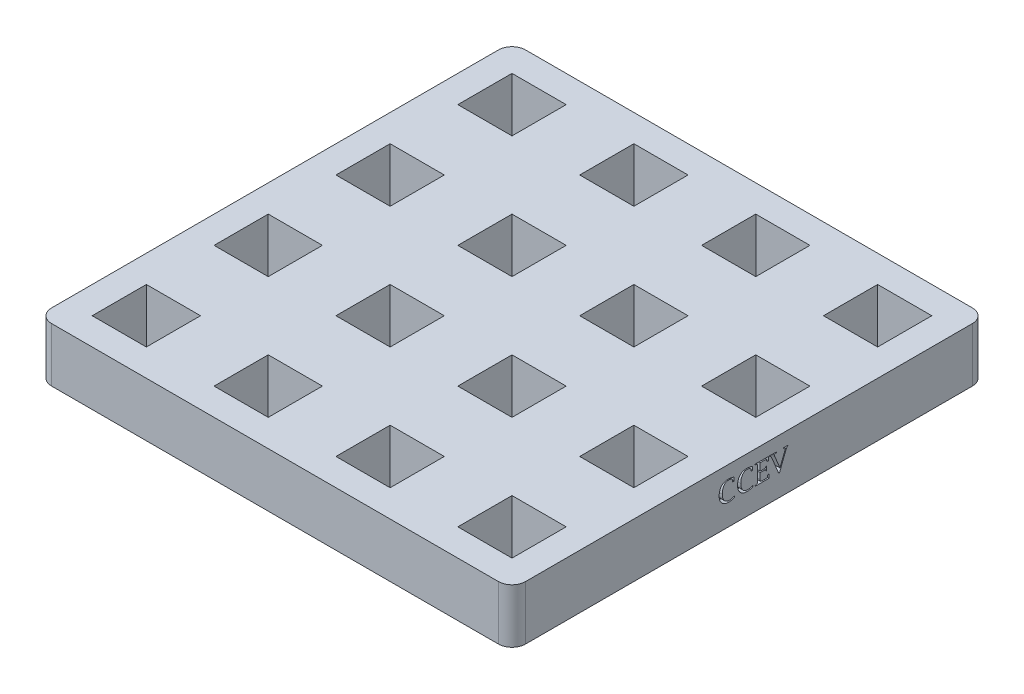
from build123d import *

# Parameters (mm, degrees)
SKETCH1_W           = 88.9
SKETCH1_H           = 88.9
SKETCH1_W_2         = 10.16
SKETCH1_H_2         = 10.16
BOSS_EXTRUDE1_DEPTH = 10.16
CUT_EXTRUDE2_DEPTH  = 1.27
FILLET1_R           = 2.54


with BuildPart() as part:
    # Sketch1 → Boss-Extrude1 (new body)
    with BuildSketch(Plane(origin=(0, 0, 0), x_dir=(1, 0, 0), z_dir=(0, 1, 0))):
        with Locations((44.45, -44.45)):
            Rectangle(SKETCH1_W, SKETCH1_H)
        with Locations((33.02, -10.16)):
            Rectangle(SKETCH1_W_2, SKETCH1_H_2, mode=Mode.SUBTRACT)
        with Locations((10.16, -10.16)):
            Rectangle(SKETCH1_W_2, SKETCH1_H_2, mode=Mode.SUBTRACT)
        with Locations((55.88, -10.16)):
            Rectangle(SKETCH1_W_2, SKETCH1_H_2, mode=Mode.SUBTRACT)
        with Locations((78.74, -10.16)):
            Rectangle(SKETCH1_W_2, SKETCH1_H_2, mode=Mode.SUBTRACT)
        with Locations((33.02, -33.02)):
            Rectangle(SKETCH1_W_2, SKETCH1_H_2, mode=Mode.SUBTRACT)
        with Locations((55.88, -33.02)):
            Rectangle(SKETCH1_W_2, SKETCH1_H_2, mode=Mode.SUBTRACT)
        with Locations((78.74, -33.02)):
            Rectangle(SKETCH1_W_2, SKETCH1_H_2, mode=Mode.SUBTRACT)
        with Locations((33.02, -55.88)):
            Rectangle(SKETCH1_W_2, SKETCH1_H_2, mode=Mode.SUBTRACT)
        with Locations((55.88, -55.88)):
            Rectangle(SKETCH1_W_2, SKETCH1_H_2, mode=Mode.SUBTRACT)
        with Locations((78.74, -55.88)):
            Rectangle(SKETCH1_W_2, SKETCH1_H_2, mode=Mode.SUBTRACT)
        with Locations((33.02, -78.74)):
            Rectangle(SKETCH1_W_2, SKETCH1_H_2, mode=Mode.SUBTRACT)
        with Locations((55.88, -78.74)):
            Rectangle(SKETCH1_W_2, SKETCH1_H_2, mode=Mode.SUBTRACT)
        with Locations((78.74, -78.74)):
            Rectangle(SKETCH1_W_2, SKETCH1_H_2, mode=Mode.SUBTRACT)
        with Locations((10.16, -33.02)):
            Rectangle(SKETCH1_W_2, SKETCH1_H_2, mode=Mode.SUBTRACT)
        with Locations((10.16, -55.88)):
            Rectangle(SKETCH1_W_2, SKETCH1_H_2, mode=Mode.SUBTRACT)
        with Locations((10.16, -78.74)):
            Rectangle(SKETCH1_W_2, SKETCH1_H_2, mode=Mode.SUBTRACT)
    extrude(amount=BOSS_EXTRUDE1_DEPTH)

    # Sketch3 → Cut-Extrude2 (cut)
    with BuildSketch(Plane(origin=(88.9, 0, 0), x_dir=(0, 0, -1), z_dir=(1, 0, 0))):
        with BuildLine():
            add(Edge.make_bspline(
                [(-47.143700699, 4.285314676), (-47.184685, 4.26307936), (-47.266892715, 4.218479002), (-47.396440466, 4.16267377), (-47.530482003, 4.115100858), (-47.66953927, 4.075984169), (-47.813710656, 4.045866927), (-47.962867146, 4.024480822), (-48.117035844, 4.01108947), (-48.221454478, 4.009522956), (-48.274542941, 4.00872651)],
                knots=[0, 0, 0, 0, 0.950097763, 1.905738653, 2.871688724, 3.847851376, 4.848060568, 5.871763302, 6.917963107, 8, 8, 8, 8], degree=3))
            add(Edge.make_bspline(
                [(-48.274542941, 4.00872651), (-48.341364018, 4.010174823), (-48.472084907, 4.013008134), (-48.662554011, 4.037248798), (-48.842518678, 4.076283775), (-49.011030142, 4.133004539), (-49.169107063, 4.204107624), (-49.316017016, 4.292174019), (-49.451626441, 4.396272751), (-49.576036708, 4.515398595), (-49.686469564, 4.648774633), (-49.783871499, 4.793842529), (-49.866337949, 4.950658186), (-49.932372813, 5.11976799), (-49.984234523, 5.299914249), (-50.021509532, 5.491724077), (-50.044120797, 5.695081268), (-50.046605356, 5.834581126), (-50.047876443, 5.905948461)],
                knots=[0, 0, 0, 0, 1.0907127, 2.133741934, 3.129613494, 4.092881734, 5.031519219, 5.954636873, 6.883025615, 7.817429068, 8.761096259, 9.704885592, 10.665853524, 11.647925027, 12.664084858, 13.722792364, 14.834993506, 16, 16, 16, 16], degree=3))
            add(Edge.make_bspline(
                [(-50.047876443, 5.905948461), (-50.046504565, 5.978268141), (-50.043832278, 6.11914), (-50.022789266, 6.324341803), (-49.987933102, 6.517419663), (-49.938264127, 6.697982596), (-49.875004267, 6.866401951), (-49.796771669, 7.021963916), (-49.705253467, 7.165685024), (-49.598831823, 7.295686418), (-49.479821095, 7.412030173), (-49.348860807, 7.513365753), (-49.206565881, 7.599117733), (-49.052613455, 7.66833081), (-48.887420317, 7.722378592), (-48.711065062, 7.761030368), (-48.523423982, 7.784336929), (-48.39465813, 7.787262907), (-48.328564067, 7.788764779)],
                knots=[0, 0, 0, 0, 1.198437993, 2.334443252, 3.414667221, 4.446694533, 5.434080735, 6.391511889, 7.327567475, 8.252356355, 9.169726966, 10.0802973, 10.990685018, 11.916765772, 12.871878647, 13.866328085, 14.904810219, 16, 16, 16, 16], degree=3))
            add(Edge.make_bspline(
                [(-48.328564067, 7.788764779), (-48.292535173, 7.788160024), (-48.217502334, 7.786900575), (-48.101192253, 7.777752223), (-47.976761016, 7.763188329), (-47.844186383, 7.742807823), (-47.703415896, 7.716939563), (-47.554587432, 7.684864886), (-47.397715223, 7.647592435), (-47.290811593, 7.619039761), (-47.235896754, 7.604372669)],
                knots=[0, 0, 0, 0, 0.778211485, 1.620683054, 2.518725369, 3.483977919, 4.517483666, 5.609946115, 6.772264103, 8, 8, 8, 8], degree=3))
            Line((-47.235896754, 7.604372669), (-47.235896754, 6.912902254))
            Line((-47.235896754, 6.912902254), (-47.512484921, 6.912902254))
            Line((-47.512484921, 6.912902254), (-47.512484921, 6.960440845))
            add(Edge.make_bspline(
                [(-47.512484921, 6.960440845), (-47.512484921, 6.98421014), (-47.512484921, 7.031268543), (-47.512484921, 7.078326947), (-47.512484921, 7.101616054)],
                knots=[0, 0, 0, 0, 1.010204082, 2, 2, 2, 2], degree=3))
            add(Edge.make_bspline(
                [(-47.512484921, 7.101616054), (-47.513264842, 7.120617659), (-47.514785028, 7.157654717), (-47.524152336, 7.212028887), (-47.540841922, 7.26307757), (-47.563813484, 7.311449349), (-47.595122106, 7.355356918), (-47.630833242, 7.397862715), (-47.674861574, 7.435804612), (-47.724492485, 7.471097535), (-47.779843361, 7.502495814), (-47.840057368, 7.530049764), (-47.905161342, 7.553091235), (-47.97536449, 7.571446227), (-48.050049494, 7.586952518), (-48.129824154, 7.596368922), (-48.213918143, 7.603277877), (-48.271646062, 7.604002024), (-48.301193363, 7.604372669)],
                knots=[0, 0, 0, 0, 0.872940392, 1.70149544, 2.524527953, 3.333401312, 4.150129811, 4.994603991, 5.877449129, 6.810717511, 7.788717292, 8.795394151, 9.848766788, 10.956224994, 12.126265042, 13.349109787, 14.643175601, 16, 16, 16, 16], degree=3))
            add(Edge.make_bspline(
                [(-48.301193363, 7.604372669), (-48.343782483, 7.603036197), (-48.427369247, 7.600413195), (-48.549488051, 7.578327432), (-48.664802172, 7.541566155), (-48.773339273, 7.489547501), (-48.875492616, 7.423793561), (-48.970417033, 7.342724959), (-49.058850403, 7.247504119), (-49.139449678, 7.13824451), (-49.212091302, 7.017081382), (-49.275515819, 6.885377204), (-49.329317935, 6.744151341), (-49.373574215, 6.593183545), (-49.406772679, 6.432425926), (-49.431351081, 6.261915644), (-49.445657664, 6.081702416), (-49.44760508, 5.958314281), (-49.448602083, 5.895144236)],
                knots=[0, 0, 0, 0, 0.888373946, 1.743551007, 2.580294788, 3.407379563, 4.248314273, 5.108731313, 6.00576896, 6.954874221, 7.937159125, 8.950188932, 10.001809612, 11.088010484, 12.230028994, 13.42485153, 14.681621673, 16, 16, 16, 16], degree=3))
            add(Edge.make_bspline(
                [(-49.448602083, 5.895144236), (-49.447572011, 5.831716162), (-49.44557022, 5.708453247), (-49.42788412, 5.528897929), (-49.399624151, 5.359991457), (-49.359088793, 5.201806839), (-49.308552453, 5.053752509), (-49.244373377, 4.917174534), (-49.170707123, 4.790076463), (-49.083778174, 4.675522611), (-48.987074178, 4.572733092), (-48.88102008, 4.482875189), (-48.765475428, 4.407424825), (-48.641091237, 4.345946181), (-48.507924168, 4.297104049), (-48.365126077, 4.264201453), (-48.213998619, 4.242268925), (-48.110160148, 4.240249927), (-48.057017872, 4.239216648)],
                knots=[0, 0, 0, 0, 1.242005494, 2.413650741, 3.529974997, 4.592937592, 5.608668543, 6.589038791, 7.54391707, 8.480640935, 9.398755183, 10.303097998, 11.196518338, 12.094493543, 13.015313349, 13.967687329, 14.959906499, 16, 16, 16, 16], degree=3))
            add(Edge.make_bspline(
                [(-48.057017872, 4.239216648), (-48.02096602, 4.240062527), (-47.948155753, 4.241770862), (-47.83813366, 4.255434786), (-47.726245815, 4.277121978), (-47.612621386, 4.307350865), (-47.497509876, 4.346711257), (-47.380735009, 4.394528843), (-47.261766727, 4.450455365), (-47.183560317, 4.493742549), (-47.143700699, 4.515804814)],
                knots=[0, 0, 0, 0, 0.896500142, 1.810570349, 2.753391962, 3.729718686, 4.732516545, 5.777170997, 6.867086282, 8, 8, 8, 8], degree=3))
            Line((-47.143700699, 4.515804814), (-47.143700699, 4.285314676))
        make_face()
        with BuildLine():
            add(Edge.make_bspline(
                [(-43.686348623, 4.285314676), (-43.727332924, 4.26307936), (-43.809540639, 4.218479002), (-43.93908839, 4.16267377), (-44.073129927, 4.115100858), (-44.212187195, 4.075984169), (-44.356358581, 4.045866927), (-44.50551507, 4.024480822), (-44.659683768, 4.01108947), (-44.764102402, 4.009522956), (-44.817190865, 4.00872651)],
                knots=[0, 0, 0, 0, 0.950097763, 1.905738653, 2.871688724, 3.847851376, 4.848060568, 5.871763302, 6.917963107, 8, 8, 8, 8], degree=3))
            add(Edge.make_bspline(
                [(-44.817190865, 4.00872651), (-44.884011942, 4.010174823), (-45.014732831, 4.013008134), (-45.205201935, 4.037248798), (-45.385166602, 4.076283775), (-45.553678067, 4.133004539), (-45.711754987, 4.204107624), (-45.85866494, 4.292174019), (-45.994274366, 4.396272751), (-46.118684632, 4.515398595), (-46.229117488, 4.648774633), (-46.326519423, 4.793842529), (-46.408985873, 4.950658186), (-46.475020737, 5.11976799), (-46.526882447, 5.299914249), (-46.564157456, 5.491724077), (-46.586768721, 5.695081268), (-46.58925328, 5.834581126), (-46.590524367, 5.905948461)],
                knots=[0, 0, 0, 0, 1.0907127, 2.133741934, 3.129613494, 4.092881734, 5.031519219, 5.954636873, 6.883025615, 7.817429068, 8.761096259, 9.704885592, 10.665853524, 11.647925027, 12.664084858, 13.722792364, 14.834993506, 16, 16, 16, 16], degree=3))
            add(Edge.make_bspline(
                [(-46.590524367, 5.905948461), (-46.589152489, 5.978268141), (-46.586480202, 6.11914), (-46.56543719, 6.324341803), (-46.530581026, 6.517419663), (-46.480912051, 6.697982596), (-46.417652191, 6.866401951), (-46.339419593, 7.021963916), (-46.247901391, 7.165685024), (-46.141479748, 7.295686418), (-46.02246902, 7.412030173), (-45.891508731, 7.513365753), (-45.749213805, 7.599117733), (-45.595261379, 7.66833081), (-45.430068241, 7.722378592), (-45.253712986, 7.761030368), (-45.066071907, 7.784336929), (-44.937306054, 7.787262907), (-44.871211991, 7.788764779)],
                knots=[0, 0, 0, 0, 1.198437993, 2.334443252, 3.414667221, 4.446694533, 5.434080735, 6.391511889, 7.327567475, 8.252356355, 9.169726966, 10.0802973, 10.990685018, 11.916765772, 12.871878647, 13.866328085, 14.904810219, 16, 16, 16, 16], degree=3))
            add(Edge.make_bspline(
                [(-44.871211991, 7.788764779), (-44.835183097, 7.788160024), (-44.760150258, 7.786900575), (-44.643840177, 7.777752223), (-44.519408941, 7.763188329), (-44.386834307, 7.742807823), (-44.24606382, 7.716939563), (-44.097235356, 7.684864886), (-43.940363147, 7.647592435), (-43.833459517, 7.619039761), (-43.778544679, 7.604372669)],
                knots=[0, 0, 0, 0, 0.778211485, 1.620683054, 2.518725369, 3.483977919, 4.517483666, 5.609946115, 6.772264103, 8, 8, 8, 8], degree=3))
            Line((-43.778544679, 7.604372669), (-43.778544679, 6.912902254))
            Line((-43.778544679, 6.912902254), (-44.055132845, 6.912902254))
            Line((-44.055132845, 6.912902254), (-44.055132845, 6.960440845))
            add(Edge.make_bspline(
                [(-44.055132845, 6.960440845), (-44.055132845, 6.98421014), (-44.055132845, 7.031268543), (-44.055132845, 7.078326947), (-44.055132845, 7.101616054)],
                knots=[0, 0, 0, 0, 1.010204082, 2, 2, 2, 2], degree=3))
            add(Edge.make_bspline(
                [(-44.055132845, 7.101616054), (-44.055912766, 7.120617659), (-44.057432953, 7.157654717), (-44.06680026, 7.212028887), (-44.083489846, 7.26307757), (-44.106461408, 7.311449349), (-44.13777003, 7.355356918), (-44.173481166, 7.397862715), (-44.217509499, 7.435804612), (-44.267140409, 7.471097535), (-44.322491285, 7.502495814), (-44.382705292, 7.530049764), (-44.447809267, 7.553091235), (-44.518012414, 7.571446227), (-44.592697418, 7.586952518), (-44.672472078, 7.596368922), (-44.756566067, 7.603277877), (-44.814293987, 7.604002024), (-44.843841287, 7.604372669)],
                knots=[0, 0, 0, 0, 0.872940392, 1.70149544, 2.524527953, 3.333401312, 4.150129811, 4.994603991, 5.877449129, 6.810717511, 7.788717292, 8.795394151, 9.848766788, 10.956224994, 12.126265042, 13.349109787, 14.643175601, 16, 16, 16, 16], degree=3))
            add(Edge.make_bspline(
                [(-44.843841287, 7.604372669), (-44.886430407, 7.603036197), (-44.970017171, 7.600413195), (-45.092135975, 7.578327432), (-45.207450096, 7.541566155), (-45.315987197, 7.489547501), (-45.41814054, 7.423793561), (-45.513064957, 7.342724959), (-45.601498327, 7.247504119), (-45.682097602, 7.13824451), (-45.754739226, 7.017081382), (-45.818163743, 6.885377204), (-45.871965859, 6.744151341), (-45.916222139, 6.593183545), (-45.949420603, 6.432425926), (-45.973999005, 6.261915644), (-45.988305588, 6.081702416), (-45.990253004, 5.958314281), (-45.991250007, 5.895144236)],
                knots=[0, 0, 0, 0, 0.888373946, 1.743551007, 2.580294788, 3.407379563, 4.248314273, 5.108731313, 6.00576896, 6.954874221, 7.937159125, 8.950188932, 10.001809612, 11.088010484, 12.230028994, 13.42485153, 14.681621673, 16, 16, 16, 16], degree=3))
            add(Edge.make_bspline(
                [(-45.991250007, 5.895144236), (-45.990219935, 5.831716162), (-45.988218144, 5.708453247), (-45.970532044, 5.528897929), (-45.942272075, 5.359991457), (-45.901736717, 5.201806839), (-45.851200377, 5.053752509), (-45.787021302, 4.917174534), (-45.713355048, 4.790076463), (-45.626426098, 4.675522611), (-45.529722102, 4.572733092), (-45.423668004, 4.482875189), (-45.308123352, 4.407424825), (-45.183739161, 4.345946181), (-45.050572092, 4.297104049), (-44.907774001, 4.264201453), (-44.756646543, 4.242268925), (-44.652808072, 4.240249927), (-44.599665797, 4.239216648)],
                knots=[0, 0, 0, 0, 1.242005494, 2.413650741, 3.529974997, 4.592937592, 5.608668543, 6.589038791, 7.54391707, 8.480640935, 9.398755183, 10.303097998, 11.196518338, 12.094493543, 13.015313349, 13.967687329, 14.959906499, 16, 16, 16, 16], degree=3))
            add(Edge.make_bspline(
                [(-44.599665797, 4.239216648), (-44.563613944, 4.240062527), (-44.490803677, 4.241770862), (-44.380781584, 4.255434786), (-44.268893739, 4.277121978), (-44.15526931, 4.307350865), (-44.0401578, 4.346711257), (-43.923382933, 4.394528843), (-43.804414651, 4.450455365), (-43.726208241, 4.493742549), (-43.686348623, 4.515804814)],
                knots=[0, 0, 0, 0, 0.896500142, 1.810570349, 2.753391962, 3.729718686, 4.732516545, 5.777170997, 6.867086282, 8, 8, 8, 8], degree=3))
            Line((-43.686348623, 4.515804814), (-43.686348623, 4.285314676))
        make_face()
        with BuildLine():
            Line((-40.689976824, 4.100922565), (-43.317564402, 4.100922565))
            Line((-43.317564402, 4.100922565), (-43.317564402, 4.239216648))
            Line((-43.317564402, 4.239216648), (-43.270025811, 4.242097775))
            add(Edge.make_bspline(
                [(-43.270025811, 4.242097775), (-43.246240461, 4.243854333), (-43.201007682, 4.247194792), (-43.137123008, 4.254456648), (-43.080695897, 4.262469003), (-43.032355456, 4.273819324), (-42.990959551, 4.284398866), (-42.957816759, 4.298275947), (-42.931476202, 4.312357079), (-42.911487932, 4.330000307), (-42.898087494, 4.354217789), (-42.886923067, 4.384850391), (-42.876991537, 4.423936291), (-42.869374537, 4.471660941), (-42.863966174, 4.527968204), (-42.859741255, 4.593064784), (-42.856744076, 4.666796627), (-42.856639202, 4.718920958), (-42.856584125, 4.746294953)],
                knots=[0, 0, 0, 0, 1.434223856, 2.727474356, 3.867048795, 4.858481374, 5.713375648, 6.432048766, 7.014145389, 7.504681859, 8.009876932, 8.658876013, 9.464418017, 10.430606696, 11.562838439, 12.865326848, 14.353772105, 16, 16, 16, 16], degree=3))
            Line((-42.856584125, 4.746294953), (-42.856584125, 7.051196337))
            add(Edge.make_bspline(
                [(-42.856584125, 7.051196337), (-42.856636384, 7.078810429), (-42.856735482, 7.13117485), (-42.85973999, 7.205147217), (-42.863969524, 7.270242069), (-42.869364561, 7.326554537), (-42.877020696, 7.374263851), (-42.886786278, 7.413175587), (-42.898069914, 7.443298618), (-42.911500144, 7.466879962), (-42.931755592, 7.483584623), (-42.957618534, 7.497976636), (-42.991184798, 7.510604266), (-43.032209808, 7.521857706), (-43.080896763, 7.53160858), (-43.137012195, 7.541273628), (-43.201029334, 7.548015897), (-43.246247923, 7.551434841), (-43.270025811, 7.553232669)],
                knots=[0, 0, 0, 0, 1.663492872, 3.154470594, 4.459175079, 5.59333322, 6.561165788, 7.368078355, 8.00468548, 8.498392893, 8.980088247, 9.563175259, 10.277674215, 11.13402302, 12.124082947, 13.267885073, 14.563335932, 16, 16, 16, 16], degree=3))
            Line((-43.270025811, 7.553232669), (-43.317564402, 7.558274641))
            Line((-43.317564402, 7.558274641), (-43.317564402, 7.696568724))
            Line((-43.317564402, 7.696568724), (-40.828270907, 7.696568724))
            Line((-40.828270907, 7.696568724), (-40.828270907, 7.005098309))
            Line((-40.828270907, 7.005098309), (-41.104859073, 7.005098309))
            Line((-41.104859073, 7.005098309), (-41.109901045, 7.054077463))
            add(Edge.make_bspline(
                [(-41.109901045, 7.054077463), (-41.111449795, 7.081937577), (-41.11436208, 7.13432599), (-41.120417027, 7.207760902), (-41.125712703, 7.271224633), (-41.13238139, 7.324267614), (-41.138321282, 7.367130462), (-41.14560607, 7.399694497), (-41.151976203, 7.42230316), (-41.16055357, 7.438621449), (-41.178085438, 7.445156966), (-41.201554361, 7.451771135), (-41.236728238, 7.454717054), (-41.281677189, 7.45977402), (-41.337767205, 7.461707268), (-41.404209628, 7.465446487), (-41.481574172, 7.465174714), (-41.536550689, 7.465764421), (-41.56583935, 7.466078586)],
                knots=[0, 0, 0, 0, 1.682356696, 3.163518976, 4.442725569, 5.521898355, 6.385906316, 7.053251075, 7.524801867, 7.817933519, 8.109272299, 8.604453009, 9.304744283, 10.220905803, 11.337117878, 12.684699471, 14.233778341, 16, 16, 16, 16], degree=3))
            Line((-41.56583935, 7.466078586), (-42.349505821, 7.466078586))
            Line((-42.349505821, 7.466078586), (-42.349505821, 6.083137755))
            Line((-42.349505821, 6.083137755), (-41.658035405, 6.083137755))
            add(Edge.make_bspline(
                [(-41.658035405, 6.083137755), (-41.638585037, 6.082973762), (-41.601838784, 6.08266394), (-41.549758799, 6.084715206), (-41.50336386, 6.085464517), (-41.463063891, 6.088742506), (-41.42844771, 6.09138932), (-41.399804906, 6.094843024), (-41.376936905, 6.099006425), (-41.358758209, 6.103721377), (-41.34404917, 6.112674086), (-41.331924364, 6.12672904), (-41.322270028, 6.146276653), (-41.312438015, 6.1701375), (-41.306186812, 6.199955944), (-41.299080663, 6.234619275), (-41.295518501, 6.274945656), (-41.293303527, 6.303546525), (-41.292132311, 6.318669865)],
                knots=[0, 0, 0, 0, 1.750346813, 3.306810787, 4.690475985, 5.925230668, 6.944535533, 7.815631037, 8.519176265, 9.038697147, 9.49454414, 10.04547331, 10.683585927, 11.450028129, 12.361978174, 13.417296017, 14.634338332, 16, 16, 16, 16], degree=3))
            Line((-41.292132311, 6.318669865), (-41.289251184, 6.359725921))
            Line((-41.289251184, 6.359725921), (-41.150957101, 6.359725921))
            Line((-41.150957101, 6.359725921), (-41.150957101, 5.576059451))
            Line((-41.150957101, 5.576059451), (-41.289251184, 5.576059451))
            Line((-41.289251184, 5.576059451), (-41.292132311, 5.616395225))
            add(Edge.make_bspline(
                [(-41.292132311, 5.616395225), (-41.294087109, 5.642188907), (-41.297571604, 5.688167023), (-41.310990285, 5.748382173), (-41.328586674, 5.79322764), (-41.352880474, 5.817823401), (-41.376517588, 5.828685727), (-41.399743591, 5.834553289), (-41.428370658, 5.840189284), (-41.46294164, 5.845432033), (-41.503363132, 5.848709789), (-41.549737513, 5.850667106), (-41.601844824, 5.852147164), (-41.638586672, 5.8524744), (-41.658035405, 5.852647617)],
                knots=[0, 0, 0, 0, 1.775991818, 3.165765901, 4.237076321, 5.04274036, 5.463690792, 6.012543005, 6.686063696, 7.47064192, 8.415384781, 9.473251275, 10.662504301, 12, 12, 12, 12], degree=3))
            Line((-41.658035405, 5.852647617), (-42.349505821, 5.852647617))
            Line((-42.349505821, 5.852647617), (-42.349505821, 4.741252981))
            add(Edge.make_bspline(
                [(-42.349505821, 4.741252981), (-42.349092951, 4.719406585), (-42.348307694, 4.677855776), (-42.346157573, 4.618884664), (-42.339767203, 4.566608884), (-42.333496819, 4.520386411), (-42.3229725, 4.480862698), (-42.312212098, 4.446984705), (-42.297593436, 4.420276779), (-42.281181316, 4.398039845), (-42.258442446, 4.381606863), (-42.230021374, 4.368314181), (-42.194935621, 4.356793553), (-42.153082677, 4.348063283), (-42.104631917, 4.339653474), (-42.048954047, 4.335490523), (-41.986545397, 4.331310005), (-41.942556372, 4.331377384), (-41.919497656, 4.331412704)],
                knots=[0, 0, 0, 0, 1.439586269, 2.738024779, 3.883770786, 4.908264219, 5.805872399, 6.576152683, 7.241357454, 7.804542437, 8.380246611, 9.06636846, 9.866592182, 10.806668816, 11.880514564, 13.103353883, 14.481599867, 16, 16, 16, 16], degree=3))
            Line((-41.919497656, 4.331412704), (-41.519741322, 4.331412704))
            add(Edge.make_bspline(
                [(-41.519741322, 4.331412704), (-41.486845284, 4.331497985), (-41.424646889, 4.331659231), (-41.33702664, 4.334226753), (-41.26058273, 4.336245403), (-41.195568392, 4.341901679), (-41.141555662, 4.346628086), (-41.098764078, 4.354852171), (-41.066951027, 4.362660357), (-41.043182551, 4.372823587), (-41.027751402, 4.391355583), (-41.015368964, 4.416229924), (-41.004037457, 4.449971318), (-40.994379855, 4.492464719), (-40.985913756, 4.543711283), (-40.978811769, 4.603801001), (-40.973354858, 4.672780605), (-40.970327517, 4.721800479), (-40.968725835, 4.747735516)],
                knots=[0, 0, 0, 0, 1.820585629, 3.442283955, 4.851877284, 6.051462577, 7.053760755, 7.851297732, 8.457350782, 8.873349519, 9.249677194, 9.760899543, 10.408096276, 11.213893541, 12.170764456, 13.281693943, 14.561820661, 16, 16, 16, 16], degree=3))
            Line((-40.968725835, 4.747735516), (-40.96656499, 4.79239298))
            Line((-40.96656499, 4.79239298), (-40.689976824, 4.79239298))
            Line((-40.689976824, 4.79239298), (-40.689976824, 4.100922565))
        make_face()
        with BuildLine():
            Line((-38.879188675, 4.00872651), (-40.123835422, 7.047594928))
            add(Edge.make_bspline(
                [(-40.123835422, 7.047594928), (-40.136587969, 7.076633557), (-40.160838293, 7.131853598), (-40.194771914, 7.210283931), (-40.226807724, 7.278336877), (-40.254105975, 7.33743045), (-40.278440501, 7.386606745), (-40.29901117, 7.426827019), (-40.317294448, 7.456631822), (-40.335011126, 7.486173761), (-40.365465785, 7.51289165), (-40.413570069, 7.533822161), (-40.475138726, 7.547572361), (-40.520870893, 7.551229492), (-40.545920488, 7.553232669)],
                knots=[0, 0, 0, 0, 1.602672807, 3.047652762, 4.317853151, 5.403348134, 6.336598002, 7.090957004, 7.683957734, 8.104586903, 8.826031991, 9.68357985, 10.731190977, 12, 12, 12, 12], degree=3))
            Line((-40.545920488, 7.553232669), (-40.597780769, 7.558274641))
            Line((-40.597780769, 7.558274641), (-40.597780769, 7.696568724))
            Line((-40.597780769, 7.696568724), (-39.30127374, 7.696568724))
            Line((-39.30127374, 7.696568724), (-39.30127374, 7.558274641))
            Line((-39.30127374, 7.558274641), (-39.354574585, 7.558274641))
            add(Edge.make_bspline(
                [(-39.354574585, 7.558274641), (-39.383879223, 7.558140776), (-39.438697298, 7.557890364), (-39.514832282, 7.552479543), (-39.57969682, 7.545960862), (-39.63289352, 7.535746119), (-39.674873514, 7.521917435), (-39.704827707, 7.5046198), (-39.726185698, 7.484088009), (-39.728676381, 7.46691027), (-39.729841342, 7.458875769)],
                knots=[0, 0, 0, 0, 1.709845997, 3.198485699, 4.453512714, 5.511582557, 6.358080189, 7.011764801, 7.537775178, 8, 8, 8, 8], degree=3))
            add(Edge.make_bspline(
                [(-39.729841342, 7.458875769), (-39.72924067, 7.453809191), (-39.727582028, 7.439818786), (-39.719177221, 7.414138573), (-39.708250322, 7.377738548), (-39.691630403, 7.331150044), (-39.672049066, 7.273721383), (-39.646246114, 7.206070316), (-39.617155928, 7.127542567), (-39.595258996, 7.072042609), (-39.58362416, 7.042552956)],
                knots=[0, 0, 0, 0, 0.27672885, 0.764134872, 1.461408599, 2.3442464, 3.449931209, 4.758416232, 6.27759909, 8, 8, 8, 8], degree=3))
            Line((-39.58362416, 7.042552956), (-38.638614593, 4.754218051))
            Line((-38.638614593, 4.754218051), (-37.741863898, 7.046874646))
            add(Edge.make_bspline(
                [(-37.741863898, 7.046874646), (-37.732699354, 7.069667332), (-37.715933564, 7.111364703), (-37.699579184, 7.153225073), (-37.692164462, 7.172203659)],
                knots=[0, 0, 0, 0, 1.093243289, 2, 2, 2, 2], degree=3))
            add(Edge.make_bspline(
                [(-37.692164462, 7.172203659), (-37.680638064, 7.204060567), (-37.659859725, 7.261488192), (-37.635326656, 7.338958878), (-37.619142585, 7.398243902), (-37.615748369, 7.432172788), (-37.61437404, 7.445910699)],
                knots=[0, 0, 0, 0, 1.424427787, 2.56777921, 3.420089397, 4, 4, 4, 4], degree=3))
            add(Edge.make_bspline(
                [(-37.61437404, 7.445910699), (-37.615486977, 7.455105089), (-37.617734771, 7.473674949), (-37.637266009, 7.4974423), (-37.665676669, 7.516787993), (-37.705099374, 7.532246735), (-37.755272786, 7.544021017), (-37.816344089, 7.551885846), (-37.888197678, 7.55808067), (-37.939683938, 7.558206903), (-37.967312065, 7.558274641)],
                knots=[0, 0, 0, 0, 0.548919381, 1.108649406, 1.78460059, 2.616711728, 3.647171777, 4.891943598, 6.332180766, 8, 8, 8, 8], degree=3))
            Line((-37.967312065, 7.558274641), (-38.020612909, 7.558274641))
            Line((-38.020612909, 7.558274641), (-38.020612909, 7.696568724))
            Line((-38.020612909, 7.696568724), (-37.094330665, 7.696568724))
            Line((-37.094330665, 7.696568724), (-37.094330665, 7.558274641))
            Line((-37.094330665, 7.558274641), (-37.14763151, 7.552512388))
            add(Edge.make_bspline(
                [(-37.14763151, 7.552512388), (-37.172929013, 7.551054317), (-37.218613679, 7.548421193), (-37.27875113, 7.535664599), (-37.324251806, 7.518981833), (-37.352121248, 7.496073523), (-37.36700637, 7.469634551), (-37.381296415, 7.440307629), (-37.399921648, 7.400966584), (-37.422510035, 7.350895049), (-37.447633016, 7.28993756), (-37.478682711, 7.219408147), (-37.511260683, 7.137582207), (-37.53485704, 7.07974816), (-37.547387844, 7.049035492)],
                knots=[0, 0, 0, 0, 1.295098159, 2.338812901, 3.137611341, 3.756113823, 4.131287023, 4.680877057, 5.428501332, 6.358104892, 7.49251251, 8.802797856, 10.302131447, 12, 12, 12, 12], degree=3))
            Line((-37.547387844, 7.049035492), (-38.733691775, 4.00872651))
            Line((-38.733691775, 4.00872651), (-38.879188675, 4.00872651))
        make_face()
    extrude(amount=-CUT_EXTRUDE2_DEPTH, mode=Mode.SUBTRACT)

    # Fillet1
    fillet1_edges = [part.edges().sort_by_distance(p)[0] for p in [
        (0, 5.08, 0),
        (88.9, 5.08, 0),
        (88.9, 5.08, 88.9),
        (0, 5.08, 88.9),
    ]]
    fillet(fillet1_edges, radius=FILLET1_R)


solid = part.part
